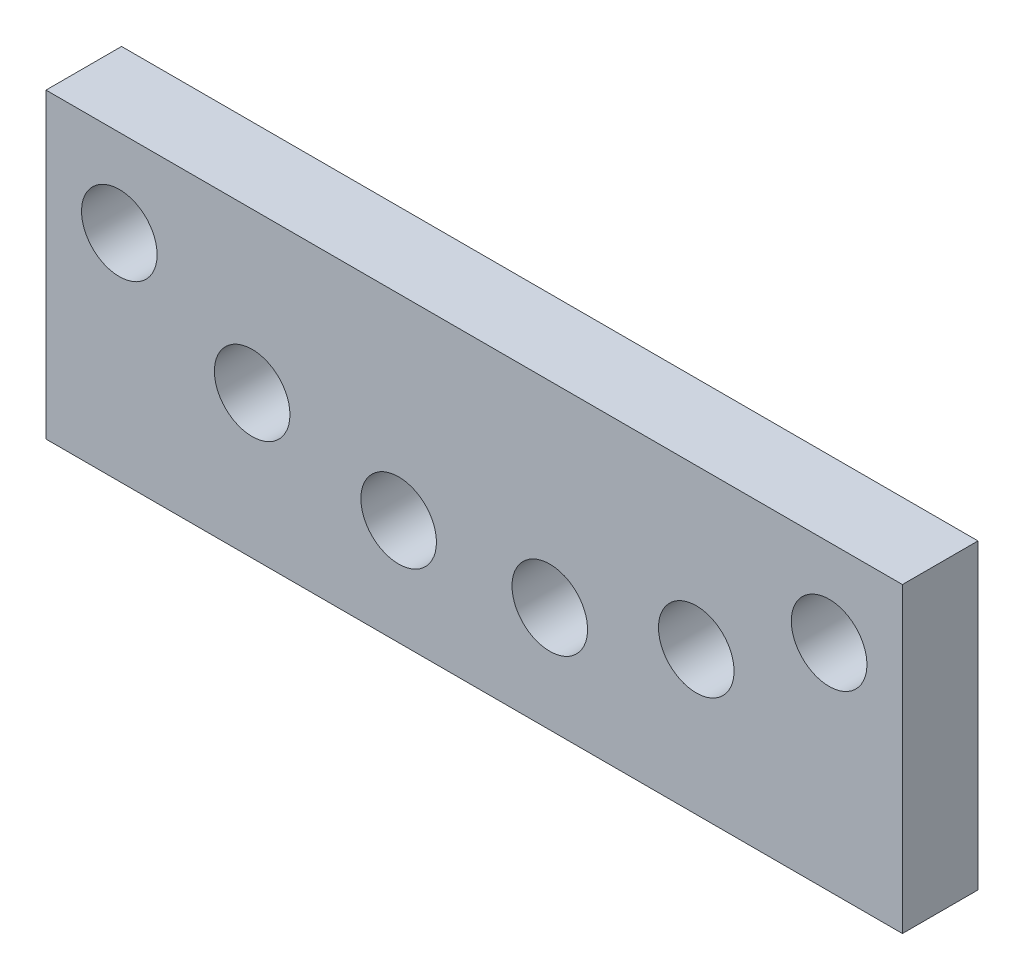
from build123d import *

# Parameters (mm, degrees)
PLAT_W                      = 60
PLAT_H                      = 15
EL_MENT_M_CANO_SOUD_1_DEPTH = 170
ESQUISSE2_R                 = 7.5
ENL_V_MAT_EXTRU_1_DEPTH     = 16


with BuildPart() as part:
    # plat → Elément mécano-soudé1 (new body)
    with BuildSketch(Plane.YZ.offset(-85)):
        Rectangle(PLAT_W, PLAT_H)
    extrude(amount=EL_MENT_M_CANO_SOUD_1_DEPTH)

    # Esquisse2 → Enlèv. mat.-Extru.1 (cut, through all)
    with BuildSketch(Plane.XY.offset(7.5)):
        with Locations((-15, -8.979692736)):
            Circle(ESQUISSE2_R)
        with Locations((-44.077931835, -1.599050475)):
            Circle(ESQUISSE2_R)
        with Locations((-70.446339823, 12.708537029)):
            Circle(ESQUISSE2_R)
        with Locations(Location((70.446339823, 12.708537029, 0), (0, 0, 180))):  # turned: the seam where the file's is
            Circle(ESQUISSE2_R)
        with Locations(Location((44.077931835, -1.599050475, 0), (0, 0, 180))):  # turned: the seam where the file's is
            Circle(ESQUISSE2_R)
        with Locations(Location((15, -8.979692736, 0), (0, 0, 180))):  # turned: the seam where the file's is
            Circle(ESQUISSE2_R)
    extrude(amount=-ENL_V_MAT_EXTRU_1_DEPTH, mode=Mode.SUBTRACT)


solid = part.part
